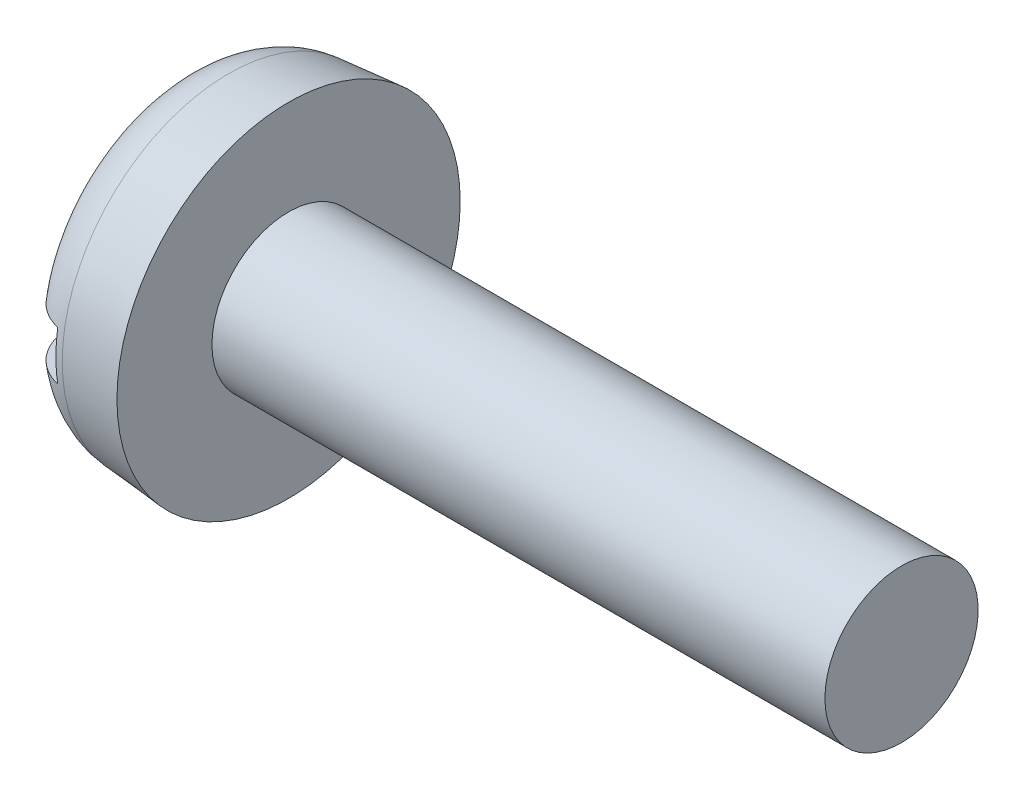
from build123d import *

# Parameters (mm, degrees)
FILLET2_R  = 0.9
SKETCH2_W  = 5.6
SKETCH2_H  = 0.8
SLOT_DEPTH = 0.7


with BuildPart() as part:
    # BodySke → Base-Revolve (revolve)
    with BuildSketch(Plane.XY):
        Polygon((1.8, 1.25), (1.8, 2.8), (0, 2.642520406), (0, 0), (11.8, 0), (11.8, 1.25), align=None)
    revolve(axis=Axis((-25.4, 0, 0), (1, 0, 0)))

    # Fillet2
    fillet2_edges = [part.edges().sort_by_distance(p)[0] for p in [
        (0, -2.642520406, 0),
    ]]
    fillet(fillet2_edges, radius=FILLET2_R)

    # Sketch2 → Slot (cut)
    with BuildSketch(Plane(origin=(0, 0, 0), x_dir=(0, 0, -1), z_dir=(1, 0, 0))):
        Rectangle(SKETCH2_W, SKETCH2_H)
    extrude(amount=SLOT_DEPTH, mode=Mode.SUBTRACT)


solid = part.part
